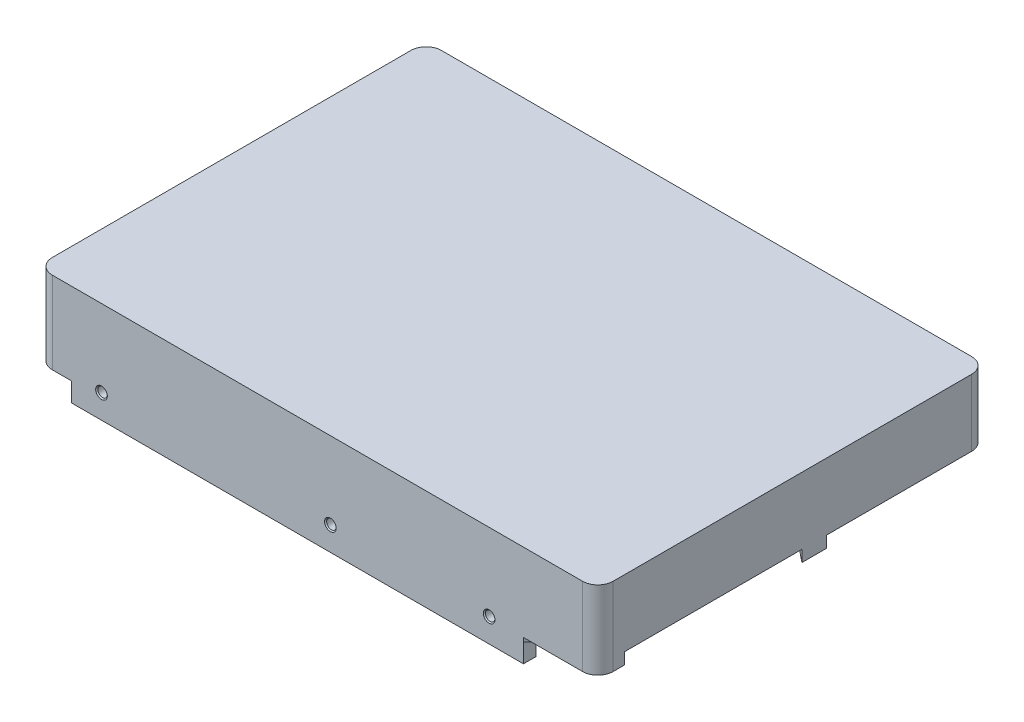
from build123d import *

# Parameters (mm, degrees)
SKETCH_4_W                   = 147
SKETCH_4_H                   = 102
EXTRUDE_1_DEPTH              = 26.5
PATTERN_LINEAR_3_COUNT       = 2
PATTERN_LINEAR_3_PITCH       = 44.45
PATTERN_LINEAR_3_COUNT_DIR2  = 2
PATTERN_LINEAR_3_PITCH_DIR2  = 95
SKETCH_10_W                  = 9
SKETCH_10_H                  = 5
CUT_EXTRUDE_1_DEPTH          = 103
SKETCH_12_W                  = 19.5
SKETCH_12_H                  = 5
CUT_EXTRUDE_2_DEPTH          = 103
CUT_EXTRUDE_3_DEPTH          = 4
CUT_EXTRUDE_4_DEPTH          = 1
CUT_EXTRUDE_7_DEPTH          = 5
SKETCH_16_W                  = 6
SKETCH_16_H                  = 3
CUT_EXTRUDE_8_DEPTH          = 4
PATTERN_LINEAR_4_COUNT       = 2
PATTERN_LINEAR_4_PITCH       = 41.61
PATTERN_LINEAR_4_COL_COUNT   = 2
PATTERN_LINEAR_4_COL_PITCH   = 101.6
MIRROR_2_COPY_1_SKETCH_W     = 6
MIRROR_2_COPY_1_SKETCH_H     = 3
MIRROR_2_COPY_1_DEPTH        = 4
MIRROR_2_COPY_2_SKETCH_W     = 6
MIRROR_2_COPY_2_SKETCH_H     = 3
MIRROR_2_COPY_2_DEPTH        = 4
PATTERN_LINEAR_1_COUNT       = 2
PATTERN_LINEAR_1_PITCH       = 41.61
PATTERN_LINEAR_1_COL_COUNT   = 2
PATTERN_LINEAR_1_COL_PITCH   = 101.6
SKETCH_17_R                  = 2.5
EXTRUDE_2_DEPTH              = 3
PATTERN_LINEAR_5_COUNT       = 2
PATTERN_LINEAR_5_PITCH       = 46.5
SKETCH_18_R                  = 2.5
EXTRUDE_3_DEPTH              = 3
DRAFT_1_ANGLE                = 2
SKETCH_19_W                  = 9
SKETCH_19_H                  = 81
CUT_EXTRUDE_9_DEPTH          = 1
SKETCH_21_W                  = 9
SKETCH_21_H                  = 42
CUT_EXTRUDE_10_DEPTH         = 4
SKETCH_22_W                  = 7
SKETCH_22_H                  = 41
SKETCH_22_H_2                = 40.5
CUT_EXTRUDE_11_DEPTH         = 6
HOLE_WIZARD_M3_3_D           = 2.5
HOLE_WIZARD_M3_3_DEPTH       = 8.5
HOLE_WIZARD_M3_3_CSINK_D     = 3.05
HOLE_WIZARD_M3_3_CSINK_ANGLE = 90
HOLE_WIZARD_M3_3_TIP         = 0.751075774
FILLET_1_R                   = 4


with BuildPart() as part:
    # 草图4 → 凸台-拉伸1 (new body)
    with BuildSketch(Plane(origin=(0, 0, 0), x_dir=(1, 0, 0), z_dir=(0, 1, 0))):
        Rectangle(SKETCH_4_W, SKETCH_4_H)
    extrude(amount=EXTRUDE_1_DEPTH)

    # 草图9 → M3 螺纹孔2 (revolve, cut)
    with BuildSketch(Plane(origin=(32.22, 0, 47.5), x_dir=(0, 0, -1), z_dir=(1, 0, 0))):
        Polygon((0, 0), (0, 8.251075774), (1.25, 7.5), (1.25, 0.275), (1.525, 0), align=None)
    hole_wizard_m3_2 = revolve(axis=Axis((32.22, -6.35, 47.5), (0, 1, 0)), mode=Mode.SUBTRACT)

    # 阵列(线性)3: Hole Wizard M3 _2 2 × 2
    with Locations(*[(-i * PATTERN_LINEAR_3_PITCH, 0, -j * PATTERN_LINEAR_3_PITCH_DIR2) for i in range(PATTERN_LINEAR_3_COUNT) for j in range(PATTERN_LINEAR_3_COUNT_DIR2) if (i, j) != (0, 0)]):
        add(hole_wizard_m3_2, mode=Mode.SUBTRACT)

    # 草图10 → 切除-拉伸1 (cut, through all)
    with BuildSketch(Plane.XY.offset(51)):
        with Locations((-69, 2.5)):
            Rectangle(SKETCH_10_W, SKETCH_10_H)
    extrude(amount=-CUT_EXTRUDE_1_DEPTH, mode=Mode.SUBTRACT)

    # 草图12 → 切除-拉伸2 (cut, through all)
    with BuildSketch(Plane.XY.offset(51)):
        with Locations((63.75, 2.5)):
            Rectangle(SKETCH_12_W, SKETCH_12_H)
    extrude(amount=-CUT_EXTRUDE_2_DEPTH, mode=Mode.SUBTRACT)

    # 草图13 → 切除-拉伸3 (cut)
    with BuildSketch(Plane.XZ.offset(-5)):
        Polygon((54, -51), (73.5, -31.5), (73.5, -51), align=None)
    extrude(amount=-CUT_EXTRUDE_3_DEPTH, mode=Mode.SUBTRACT)

    # 草图14 → 切除-拉伸4 (cut)
    with BuildSketch(Plane.XZ.offset(-5)):
        Polygon((54, 51), (73.5, 31.5), (73.5, 51), align=None)
    extrude(amount=-CUT_EXTRUDE_4_DEPTH, mode=Mode.SUBTRACT)

    # 草图15 → 切除-拉伸7 (cut)
    with BuildSketch(Plane.XZ):
        with BuildLine():
            Line((54, 47.7), (35.714281042, 47.7))
            ThreePointArc((35.714281042, 47.7), (32.22, 44), (28.725718958, 47.7))
            Line((28.725718958, 47.7), (-8.735718958, 47.7))
            ThreePointArc((-8.735718958, 47.7), (-12.23, 44), (-15.724281042, 47.7))
            Line((-15.724281042, 47.7), (-64.5, 47.7))
            Line((-64.5, 47.7), (-64.5, -47.7))
            Line((-64.5, -47.7), (-15.724281042, -47.7))
            ThreePointArc((-15.724281042, -47.7), (-12.23, -44), (-8.735718958, -47.7))
            Line((-8.735718958, -47.7), (28.725718958, -47.7))
            ThreePointArc((28.725718958, -47.7), (32.22, -44), (35.714281042, -47.7))
            Line((35.714281042, -47.7), (54, -47.7))
            Line((54, -47.7), (54, 47.7))
        make_face()
    extrude(amount=-CUT_EXTRUDE_7_DEPTH, mode=Mode.SUBTRACT)

    # 草图16 → 切除-拉伸8 (cut)
    with BuildSketch(Plane.XZ.offset(-5)):
        with Locations((45, 46.2)):
            Rectangle(SKETCH_16_W, SKETCH_16_H)
    cut_extrude_8 = extrude(amount=-CUT_EXTRUDE_8_DEPTH, mode=Mode.SUBTRACT)

    # 阵列(线性)4: 切除-拉伸8 ×2
    with Locations(*[(-i * PATTERN_LINEAR_4_PITCH, 0, 0) for i in range(1, PATTERN_LINEAR_4_COUNT)]):
        add(cut_extrude_8, mode=Mode.SUBTRACT)

    # 阵列(线性)4 col: 切除-拉伸8 ×2
    with Locations(*[(-i * PATTERN_LINEAR_4_COL_PITCH, 0, 0) for i in range(1, PATTERN_LINEAR_4_COL_COUNT)]):
        add(cut_extrude_8, mode=Mode.SUBTRACT)

    # 镜向2: 切除-拉伸8 across plane
    add(cut_extrude_8.mirror(Plane.XY), mode=Mode.SUBTRACT)

    # 镜向2 copy 1 sketch → 镜向2 copy 1 (cut)
    with BuildSketch(Plane(origin=(-41.61, 5, 0), x_dir=(1, 0, 0), z_dir=(0, -1, 0))):
        with Locations((45, -46.2)):
            Rectangle(MIRROR_2_COPY_1_SKETCH_W, MIRROR_2_COPY_1_SKETCH_H)
    extrude(amount=-MIRROR_2_COPY_1_DEPTH, mode=Mode.SUBTRACT)

    # 镜向2 copy 2 sketch → 镜向2 copy 2 (cut)
    with BuildSketch(Plane(origin=(-101.6, 5, 0), x_dir=(1, 0, 0), z_dir=(0, -1, 0))):
        with Locations((45, -46.2)):
            Rectangle(MIRROR_2_COPY_2_SKETCH_W, MIRROR_2_COPY_2_SKETCH_H)
    extrude(amount=-MIRROR_2_COPY_2_DEPTH, mode=Mode.SUBTRACT)

    # 草图7 → M3 螺纹孔1 (revolve, cut)
    with BuildSketch(Plane(origin=(45, 6.25, 51), x_dir=(0, -1, 0), z_dir=(1, 0, 0))):
        Polygon((0, 0), (0, 5.751075774), (1.25, 5), (1.25, 0.275), (1.525, 0), align=None)
    hole_wizard_m3_1 = revolve(axis=Axis((45, 6.25, 57.35), (0, 0, -1)), mode=Mode.SUBTRACT)

    # 阵列(线性)1: M3 螺纹孔1 ×2
    with Locations(*[(-i * PATTERN_LINEAR_1_PITCH, 0, 0) for i in range(1, PATTERN_LINEAR_1_COUNT)]):
        add(hole_wizard_m3_1, mode=Mode.SUBTRACT)

    # 阵列(线性)1 col: M3 螺纹孔1 ×2
    with Locations(*[(-i * PATTERN_LINEAR_1_COL_PITCH, 0, 0) for i in range(1, PATTERN_LINEAR_1_COL_COUNT)]):
        add(hole_wizard_m3_1, mode=Mode.SUBTRACT)

    # 镜向4: M3 螺纹孔1 across plane
    add(hole_wizard_m3_1.mirror(Plane.XY), mode=Mode.SUBTRACT)

    # 镜向4 copy 1 sketch → 镜向4 copy 1 (revolve, cut)
    with BuildSketch(Plane(origin=(3.39, 6.25, -51), x_dir=(0, -1, 0), z_dir=(1, 0, 0))):
        Polygon((0, 0), (0, -5.751075774), (1.25, -5), (1.25, -0.275), (1.525, 0), align=None)
    revolve(axis=Axis((3.39, 6.25, -57.35), (0, 0, -1)), mode=Mode.SUBTRACT)

    # 镜向4 copy 2 sketch → 镜向4 copy 2 (revolve, cut)
    with BuildSketch(Plane(origin=(-56.6, 6.25, -51), x_dir=(0, -1, 0), z_dir=(1, 0, 0))):
        Polygon((0, 0), (0, -5.751075774), (1.25, -5), (1.25, -0.275), (1.525, 0), align=None)
    revolve(axis=Axis((-56.6, 6.25, -57.35), (0, 0, -1)), mode=Mode.SUBTRACT)

    # 草图17 → 凸台-拉伸2 (add)
    with BuildSketch(Plane.XZ.offset(-5)):
        with Locations((57, 44)):
            Circle(SKETCH_17_R)
    extrude_2 = extrude(amount=EXTRUDE_2_DEPTH)

    # 阵列(线性)5: 凸台-拉伸2 ×2
    with Locations(*[(-i * PATTERN_LINEAR_5_PITCH, 0, 0) for i in range(1, PATTERN_LINEAR_5_COUNT)]):
        add(extrude_2)

    # 草图18 → 凸台-拉伸3 (add)
    with BuildSketch(Plane.XZ.offset(-5)):
        with Locations((10.5, -30)):
            Circle(SKETCH_18_R)
        with Locations((42.5, -16)):
            Circle(SKETCH_18_R)
        with Locations((59, -16)):
            Circle(SKETCH_18_R)
        with Locations((17, 9.5)):
            Circle(SKETCH_18_R)
    extrude(amount=EXTRUDE_3_DEPTH)

    # 拔模1
    draft_1_faces = [part.faces().sort_by_distance(p)[0] for p in [
        (8, 3.5, -30),
        (56.5, 3.5, -16),
        (40, 3.5, -16),
        (14.5, 3.5, 9.5),
        (8, 3.5, 44),
        (54.5, 3.5, 44),
    ]]
    draft(draft_1_faces, Plane(origin=(-73.5, 5, -51), x_dir=(0, 0, -1), z_dir=(0, -1, 0)), DRAFT_1_ANGLE)

    # 草图19 → 切除-拉伸9 (cut)
    with BuildSketch(Plane.XZ.offset(-5)):
        with Locations((69, 0)):
            Rectangle(SKETCH_19_W, SKETCH_19_H)
    extrude(amount=-CUT_EXTRUDE_9_DEPTH, mode=Mode.SUBTRACT)

    # 草图21 → 切除-拉伸10 (cut)
    with BuildSketch(Plane.XZ.offset(-5)):
        with Locations((69, -30)):
            Rectangle(SKETCH_21_W, SKETCH_21_H)
        with BuildLine():
            Line((73.5, 44), (69.5, 44))
            Line((69.5, 44), (69.5, 47.387489493))
            Line((69.5, 47.387489493), (66, 47.387489493))
            Line((66, 47.387489493), (66, 44))
            Line((66, 44), (64.5, 44))
            Line((64.5, 44), (64.5, -2.479274058))
            Line((64.5, -2.479274058), (68, -4.5))
            Line((68, -4.5), (68, -5.5))
            ThreePointArc((68, -5.5), (69.5, -7), (71, -5.5))
            Line((71, -5.5), (71, -4.5))
            Line((71, -4.5), (73.5, -2.5))
            Line((73.5, -2.5), (73.5, 44))
        make_face()
    extrude(amount=-CUT_EXTRUDE_10_DEPTH, mode=Mode.SUBTRACT)

    # 草图22 → 切除-拉伸11 (cut)
    with BuildSketch(Plane.XZ.offset(-9)):
        with Locations((68, 23.5)):
            Rectangle(SKETCH_22_W, SKETCH_22_H)
        with Locations((68, -29.25)):
            Rectangle(SKETCH_22_W, SKETCH_22_H_2)
    extrude(amount=-CUT_EXTRUDE_11_DEPTH, mode=Mode.SUBTRACT)

    # M3 螺纹孔3
    with Locations(Plane(origin=(0, 2, 0), x_dir=(-1, 0, 0), z_dir=(0, -1, 0))):
        with Locations((-57, -44), (-10.5, -44), (-17, -9.5), (-10.5, 30), (-42.5, 16), (-59, 16)):
            CounterSinkHole(HOLE_WIZARD_M3_3_D / 2, HOLE_WIZARD_M3_3_CSINK_D / 2, depth=HOLE_WIZARD_M3_3_DEPTH, counter_sink_angle=HOLE_WIZARD_M3_3_CSINK_ANGLE)
            with Locations((0, 0, -(HOLE_WIZARD_M3_3_DEPTH + HOLE_WIZARD_M3_3_TIP / 2))):  # 118° drill point
                Cone(0, HOLE_WIZARD_M3_3_D / 2, HOLE_WIZARD_M3_3_TIP, mode=Mode.SUBTRACT)

    # 圆角1
    fillet_1_edges = [part.edges().sort_by_distance(p)[0] for p in [
        (-73.5, 15.75, -51),
        (73.5, 17.75, -51),
        (73.5, 16.25, 51),
        (-73.5, 15.75, 51),
    ]]
    fillet(fillet_1_edges, radius=FILLET_1_R)


solid = part.part
